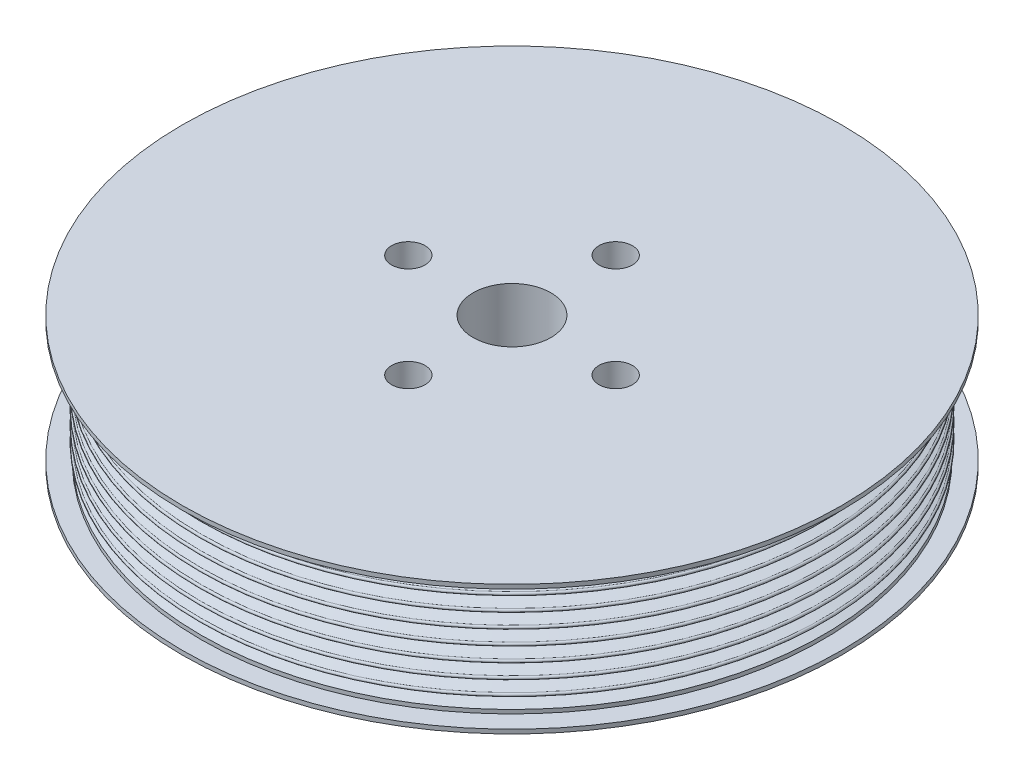
from build123d import *

# Parameters (mm, degrees)
SKETCH2_R                = 9.525
CUT_EXTRUDE1_DEPTH       = 32.74492
F_5_16_CLEARANCE_HOLE1_D = 8.2042
CIRPATTERN1_COUNT        = 4


with BuildPart() as part:
    # Sketch1 → Revolve1 (revolve)
    with BuildSketch(Plane.XY):
        with BuildLine():
            Line((76.2, 13.90396), (76.2, 14.85646))
            Line((76.2, 14.85646), (80.772, 14.85646))
            Line((80.772, 14.85646), (80.772, 15.87246))
            Line((80.772, 15.87246), (76.2, 15.87246))
            Line((76.2, 15.87246), (0, 15.87246))
            Line((0, 15.87246), (0, -15.87246))
            Line((0, -15.87246), (76.2, -15.87246))
            Line((76.2, -15.87246), (80.772, -15.87246))
            Line((80.772, -15.87246), (80.772, -14.85646))
            Line((80.772, -14.85646), (76.2, -14.85646))
            Line((76.2, -14.85646), (76.2, -13.90396))
            Line((76.2, -13.90396), (73.387627164, -12.88034))
            ThreePointArc((73.387627164, -12.88034), (73.006627164, -12.49934), (73.387627164, -12.11834))
            Line((73.387627164, -12.11834), (76.2, -11.09472))
            ThreePointArc((76.2, -11.09472), (76.581, -10.71372), (76.2, -10.33272))
            Line((76.2, -10.33272), (73.387627164, -9.3091))
            ThreePointArc((73.387627164, -9.3091), (73.006627164, -8.9281), (73.387627164, -8.5471))
            Line((73.387627164, -8.5471), (76.2, -7.52348))
            ThreePointArc((76.2, -7.52348), (76.581, -7.14248), (76.2, -6.76148))
            Line((76.2, -6.76148), (73.387627164, -5.73786))
            ThreePointArc((73.387627164, -5.73786), (73.006627164, -5.35686), (73.387627164, -4.97586))
            Line((73.387627164, -4.97586), (76.2, -3.95224))
            ThreePointArc((76.2, -3.95224), (76.581, -3.57124), (76.2, -3.19024))
            Line((76.2, -3.19024), (73.387627164, -2.16662))
            ThreePointArc((73.387627164, -2.16662), (73.006627164, -1.78562), (73.387627164, -1.40462))
            Line((73.387627164, -1.40462), (76.2, -0.381))
            ThreePointArc((76.2, -0.381), (76.581, 0), (76.2, 0.381))
            Line((76.2, 0.381), (73.387627164, 1.40462))
            ThreePointArc((73.387627164, 1.40462), (73.006627164, 1.78562), (73.387627164, 2.16662))
            Line((73.387627164, 2.16662), (76.2, 3.19024))
            ThreePointArc((76.2, 3.19024), (76.581, 3.57124), (76.2, 3.95224))
            Line((76.2, 3.95224), (73.387627164, 4.97586))
            ThreePointArc((73.387627164, 4.97586), (73.006627164, 5.35686), (73.387627164, 5.73786))
            Line((73.387627164, 5.73786), (76.2, 6.76148))
            ThreePointArc((76.2, 6.76148), (76.581, 7.14248), (76.2, 7.52348))
            Line((76.2, 7.52348), (73.387627164, 8.5471))
            ThreePointArc((73.387627164, 8.5471), (73.006627164, 8.9281), (73.387627164, 9.3091))
            Line((73.387627164, 9.3091), (76.2, 10.33272))
            ThreePointArc((76.2, 10.33272), (76.581, 10.71372), (76.2, 11.09472))
            Line((76.2, 11.09472), (73.387627164, 12.11834))
            ThreePointArc((73.387627164, 12.11834), (73.006627164, 12.49934), (73.387627164, 12.88034))
            Line((73.387627164, 12.88034), (76.2, 13.90396))
        make_face()
    revolve(axis=Axis((0, 15.87246, 0), (0, -1, 0)))

    # Sketch2 → Cut-Extrude1 (cut, through all)
    with BuildSketch(Plane(origin=(0, 15.87246, 0), x_dir=(1, 0, 0), z_dir=(0, 1, 0))):
        Circle(SKETCH2_R)
    extrude(amount=-CUT_EXTRUDE1_DEPTH, mode=Mode.SUBTRACT)

    # 5/16 Clearance Hole1 (through all)
    with Locations(Plane.XZ.offset(15.87246)):
        with Locations((0, -25.4)):
            f_5_16_clearance_hole1 = Hole(F_5_16_CLEARANCE_HOLE1_D / 2)

    # CirPattern1: 5/16 Clearance Hole1 ×4 about axis
    cirpattern1_axis = Axis((0, 0, 0), (0, 1, 0))
    for i in range(1, CIRPATTERN1_COUNT):
        add(f_5_16_clearance_hole1.rotate(cirpattern1_axis, i * 360 / CIRPATTERN1_COUNT), mode=Mode.SUBTRACT)


solid = part.part
